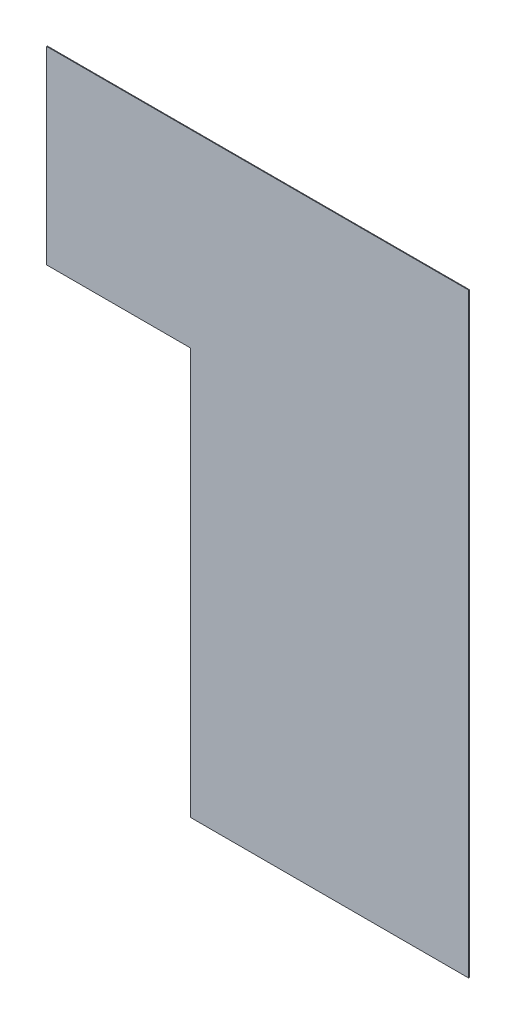
from build123d import *

# Parameters (mm, degrees)
SKETCH1_W           = 7610
SKETCH1_H           = 11129.596
BOSS_EXTRUDE1_DEPTH = 20


with BuildPart() as part:
    # Sketch1 → Boss-Extrude1 (new body)
    with BuildSketch(Plane.XY.offset(42225.220842973)):
        Polygon((-7996.617683291, 14737.077366586), (-7996.617683291, 19917.481366586), (-19546.617683291, 19917.481366586), (-19546.617683291, 14737.077366586), (-15606.617683291, 14737.077366586), align=None)
        with Locations((-11801.617683291, 9172.279366586)):
            Rectangle(SKETCH1_W, SKETCH1_H)
    extrude(amount=BOSS_EXTRUDE1_DEPTH)


solid = part.part
